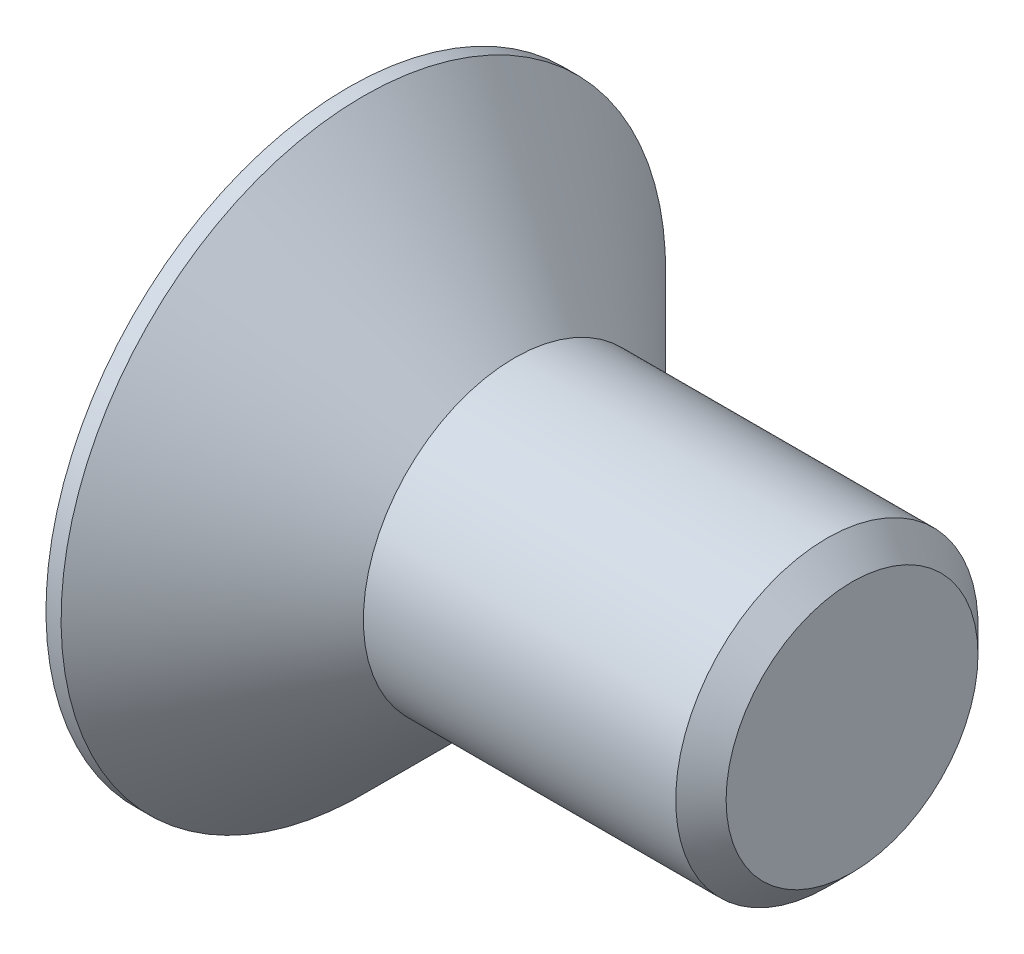
from build123d import *

# Parameters (mm, degrees)
CHANFREIN1_SIZE         = 0.5
ENL_V_MAT_EXTRU_1_DEPTH = 2.5


with BuildPart() as part:
    # Esquisse1 → Révolution1 (revolve)
    with BuildSketch(Plane.XY):
        Polygon((0, 0), (0, 6), (0.3, 6), (3.3, 3), (10, 3), (10, 0), align=None)
    revolve(axis=Axis((10, 0, 0), (-1, 0, 0)))

    # Chanfrein1
    chanfrein1_edges = [part.edges().sort_by_distance(p)[0] for p in [
        (10, -3, 0),
    ]]
    chamfer(chanfrein1_edges, length=CHANFREIN1_SIZE)

    # Esquisse2 → Enlèv. mat.-Extru.1 (cut)
    with BuildSketch(Plane.ZY):
        Polygon((0, 2.309401077), (-2, 1.154700538), (-2, -1.154700538), (0, -2.309401077), (2, -1.154700538), (2, 1.154700538), align=None)
    extrude(amount=-ENL_V_MAT_EXTRU_1_DEPTH, mode=Mode.SUBTRACT)


solid = part.part
